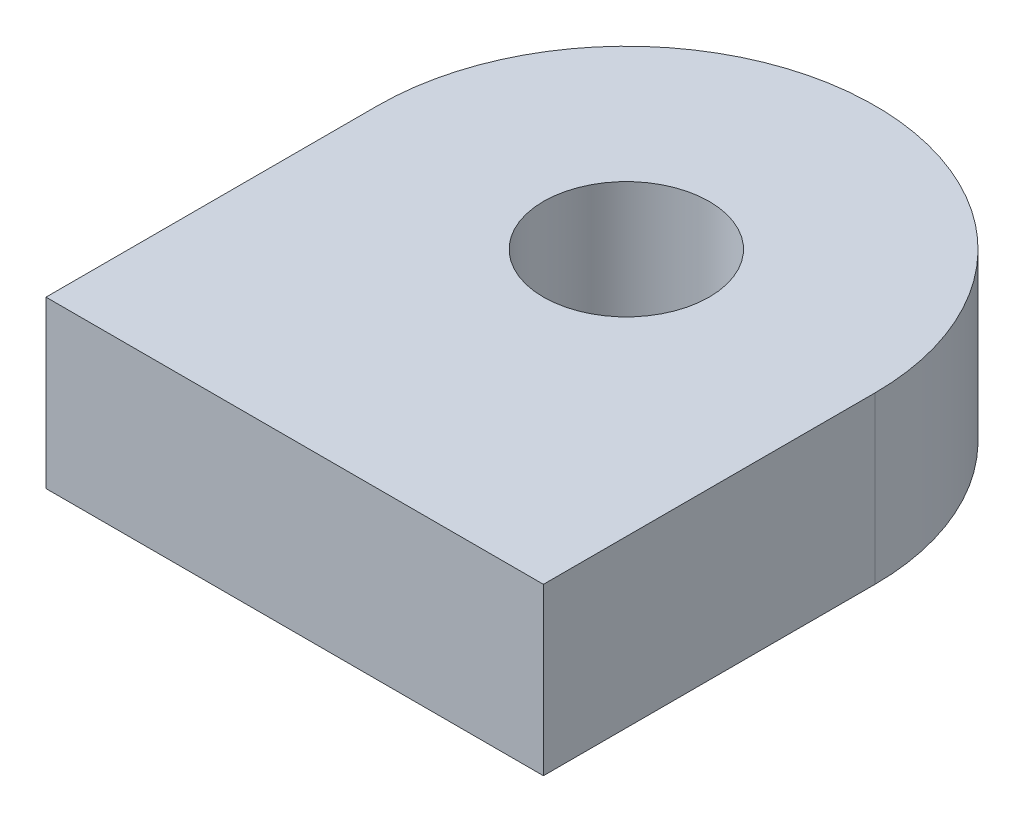
from build123d import *

# Parameters (mm, degrees)
SKETCH1_R      = 6.35
FASTENER_DEPTH = 12.7


with BuildPart() as part:
    # Sketch1 → Fastener (new body)
    with BuildSketch(Plane(origin=(0, 0, 0), x_dir=(1, 0, 0), z_dir=(0, 1, 0))):
        with BuildLine():
            Line((-19.05, 0), (-19.05, -25.4))
            Line((-19.05, -25.4), (19.05, -25.4))
            Line((19.05, -25.4), (19.05, 0))
            ThreePointArc((19.05, 0), (0, 19.05), (-19.05, 0))
        make_face()
        Circle(SKETCH1_R, mode=Mode.SUBTRACT)
    extrude(amount=FASTENER_DEPTH)


solid = part.part
